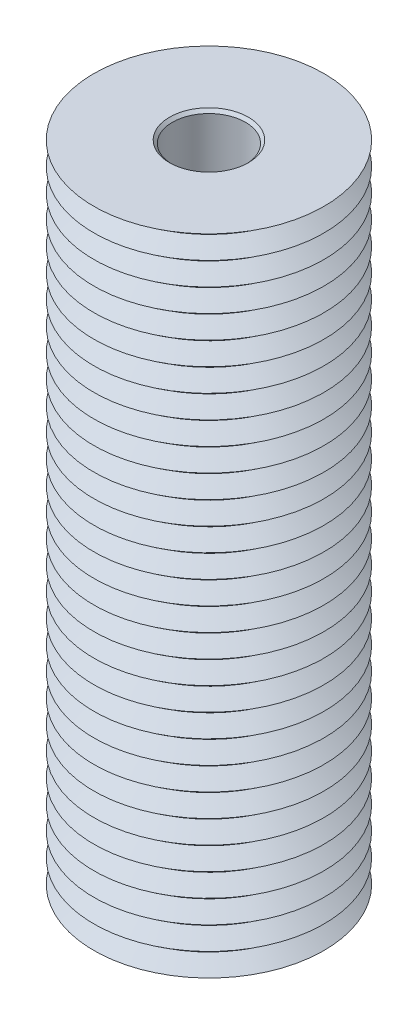
from build123d import *


with BuildPart() as part:
    # Sketch1 → Revolve1 (revolve)
    with BuildSketch(Plane.XY, mode=Mode.PRIVATE) as revolve1_sk:
        Polygon((1.7145, 0), (5, 0), (4.3235, 0.5), (5, 1), (4.3235, 1.5), (5, 2), (4.3235, 2.5), (5, 3), (4.3235, 3.5), (5, 4), (4.3235, 4.5), (5, 5), (4.3235, 5.5), (5, 6), (4.3235, 6.5), (5, 7), (4.3235, 7.5), (5, 8), (4.3235, 8.5), (5, 9), (4.3235, 9.5), (5, 10), (4.3235, 10.5), (5, 11), (4.3235, 11.5), (5, 12), (4.3235, 12.5), (5, 13), (4.3235, 13.5), (5, 14), (4.3235, 14.5), (5, 15), (4.3235, 15.5), (5, 16), (4.3235, 16.5), (5, 17), (4.3235, 17.5), (5, 18), (4.3235, 18.5), (5, 19), (4.3235, 19.5), (5, 20), (4.3235, 20.5), (5, 21), (4.3235, 21.5), (5, 22), (4.3235, 22.5), (5, 23), (4.3235, 23.5), (5, 24), (4.3235, 24.5), (5, 25), (4.3235, 25.5), (5, 26), (4.3235, 26.5), (5, 27), (4.3235, 27.5), (5, 28), (1.7145, 28), (1.5875, 27.873), (1.5875, 0.127), align=None)
    revolve(revolve1_sk.sketch.rotate(Axis((0, 0, 0), (0, 1, 0)), 90), axis=Axis((0, 0, 0), (0, 1, 0)))  # turned: the seam where the file's is


solid = part.part
